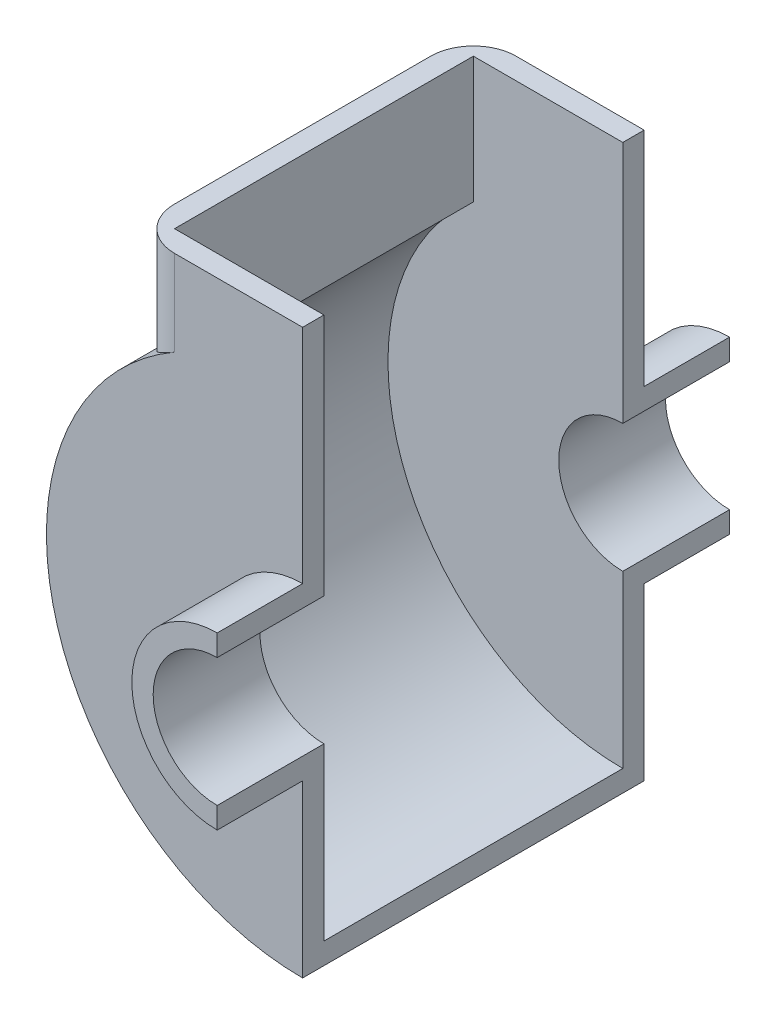
from build123d import *

# Parameters (mm, degrees)
DODANIE_WYCI_GNI_CIE1_DEPTH       = 25
DODANIE_WYCI_GNI_CIE5_DEPTH       = 5
WYCI_GNI_CIE_CIENKA_START         = -70
WYCI_GNI_CIE_CIENKA_CIANKA5_DEPTH = 70
ZAOKR_GLENIE1_R                   = 10
ZAOKR_GLENIE2_R                   = 10


with BuildPart() as part:
    # Szkic1 → Dodanie-wyciągnięcie1 (new body)
    with BuildSketch(Plane.XY):
        with BuildLine():
            Line((0, 20), (0, 15))
            ThreePointArc((0, 15), (-15, 0), (0, -15))
            Line((0, -15), (0, -20))
            ThreePointArc((0, -20), (-20, 0), (0, 20))
        make_face()
    extrude(amount=DODANIE_WYCI_GNI_CIE1_DEPTH)

    # Szkic2 → Dodanie-wyciągnięcie5 (add)
    with BuildSketch(Plane.XY):
        with BuildLine():
            Line((0, 20), (0, 72))
            Line((0, 72), (-40, 72))
            Line((-40, 72), (-40, 44.72135955))
            ThreePointArc((-40, 44.72135955), (-56.050341538, -21.409325386), (0, -60))
            Line((0, -60), (0, -20))
            ThreePointArc((0, -20), (-20, 0), (0, 20))
        make_face()
    extrude(amount=DODANIE_WYCI_GNI_CIE5_DEPTH)


with BuildPart() as body_2:
    # Lustro10: mirrored copy
    add(part.part.mirror(Plane.XY.offset(-35)))


with BuildPart() as part_1:
    add(part.part)

    add(body_2.part)  # Wyciągnięcie-cienka ścianka5 merges body 2
    # Szkic12 → Wyciągnięcie-cienka ścianka5 (add)
    with BuildSketch(Plane.XY.offset(WYCI_GNI_CIE_CIENKA_START)):
        with BuildLine():
            Line((-40, 72), (-40, 44.72135955))
            ThreePointArc((-40, 44.72135955), (-56.050341538, -21.409325386), (0, -60))
            Line((0, -60), (0, -55))
            ThreePointArc((0, -55), (-51.76124215, -18.594994247), (-35, 42.426406871))
            Line((-35, 42.426406871), (-35, 72))
            Line((-35, 72), (-40, 72))
        make_face()
    extrude(amount=WYCI_GNI_CIE_CIENKA_CIANKA5_DEPTH)

    # Zaokrąglenie1
    zaokr_glenie1_edges = [part_1.edges().sort_by_distance(p)[0] for p in [
        (-40, 58.360679775, 5),
    ]]
    fillet(zaokr_glenie1_edges, radius=ZAOKR_GLENIE1_R)

    # Zaokrąglenie2
    zaokr_glenie2_edges = [part_1.edges().sort_by_distance(p)[0] for p in [
        (-40, 58.360679775, -75),
    ]]
    fillet(zaokr_glenie2_edges, radius=ZAOKR_GLENIE2_R)


solid = part_1.part
